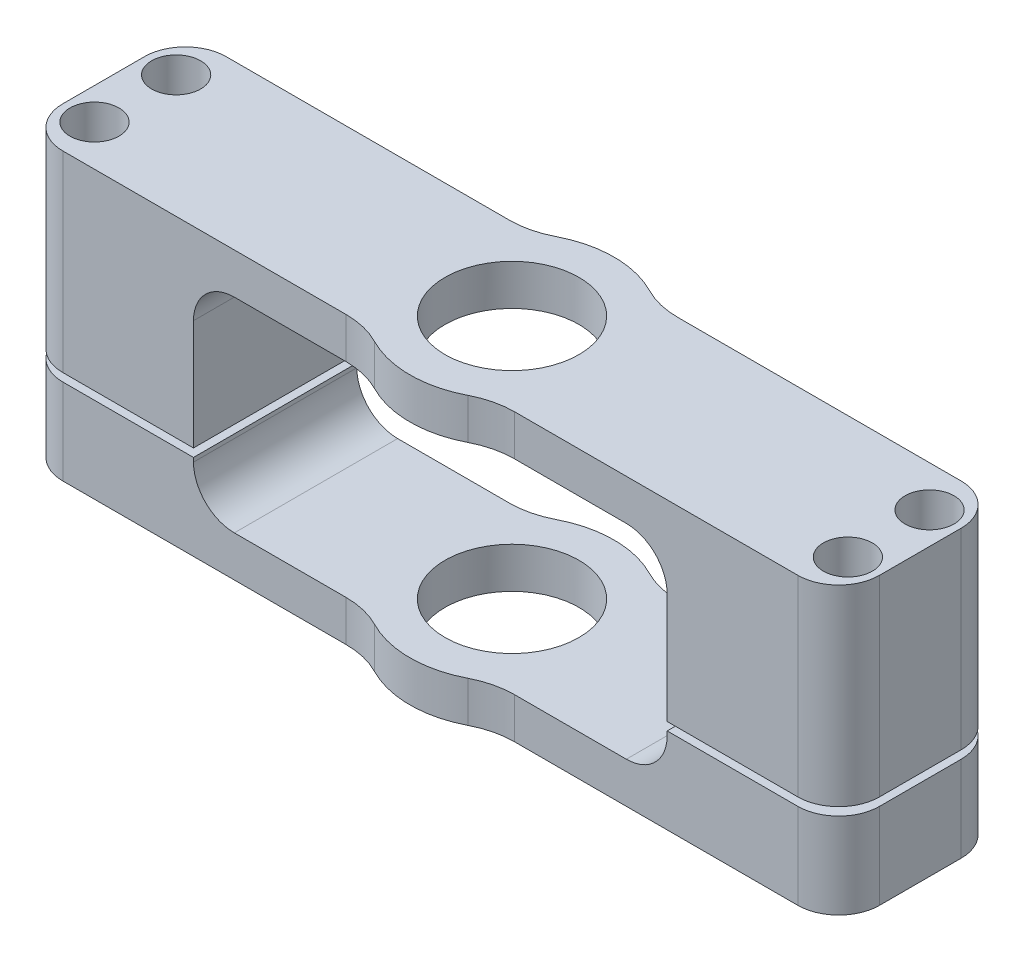
from build123d import *

# Parameters (mm, degrees)
SKETCH1_W               = 88
SKETCH1_H               = 20
BOSS_EXTRUDE1_DEPTH     = 35
SKETCH2_R               = 4.25
CUT_EXTRUDE1_DEPTH      = 21
SKETCH7_R               = 12.5
BOSS_EXTRUDE2_DEPTH     = 35
SKETCH4_R               = 8.2
CUT_EXTRUDE3_DEPTH      = 36
FILLET2_R               = 10
SKETCH10_W              = 58
SKETCH10_H              = 25
CUT_EXTRUDE5_DEPTH      = 13.5
CUT_EXTRUDE5_DEPTH_BACK = 13.5
FILLET3_R               = 5
SKETCH11_W              = 20
SKETCH11_H              = 35
BOSS_EXTRUDE3_DEPTH     = 6
SKETCH12_R              = 1.6
CUT_EXTRUDE6_DEPTH      = 36
FILLET5_R               = 5
SKETCH13_R              = 4.25
BOSS_EXTRUDE4_DEPTH     = 4
SKETCH14_W              = 100
SKETCH14_H              = 1
CUT_EXTRUDE7_DEPTH      = 23.5
SKETCH15_R              = 3
CUT_EXTRUDE8_DEPTH      = 6
CUT_EXTRUDE9_DEPTH      = 3


with BuildPart() as part:
    # Sketch1 → Boss-Extrude1 (new body)
    with BuildSketch(Plane(origin=(0, 0, 0), x_dir=(1, 0, 0), z_dir=(0, 1, 0))):
        Rectangle(SKETCH1_W, SKETCH1_H)
    extrude(amount=BOSS_EXTRUDE1_DEPTH)

    # Sketch2 → Cut-Extrude1 (cut, through all)
    with BuildSketch(Plane.XY.offset(10)):
        with Locations((-38, 11)):
            Circle(SKETCH2_R)
        with Locations((38, 11)):
            Circle(SKETCH2_R)
    extrude(amount=-CUT_EXTRUDE1_DEPTH, mode=Mode.SUBTRACT)

    # Sketch7 → Boss-Extrude2 (add)
    with BuildSketch(Plane(origin=(0, 35, 0), x_dir=(1, 0, 0), z_dir=(0, 1, 0))):
        Circle(SKETCH7_R)
    extrude(amount=-BOSS_EXTRUDE2_DEPTH)

    # Sketch4 → Cut-Extrude3 (cut, through all)
    with BuildSketch(Plane(origin=(0, 35, 0), x_dir=(1, 0, 0), z_dir=(0, 1, 0))):
        Circle(SKETCH4_R)
    extrude(amount=-CUT_EXTRUDE3_DEPTH, mode=Mode.SUBTRACT)

    # Fillet2
    fillet2_edges = [part.edges().sort_by_distance(p)[0] for p in [
        (7.5, 17.5, -10),
        (7.5, 17.5, 10),
        (-7.5, 17.5, -10),
        (-7.5, 17.5, 10),
    ]]
    fillet(fillet2_edges, radius=FILLET2_R)

    # Sketch10 → Cut-Extrude5 (cut, two sides)
    with BuildSketch(Plane.XY) as cut_extrude5_sk:
        with Locations((0, 17.5)):
            Rectangle(SKETCH10_W, SKETCH10_H)
    extrude(amount=CUT_EXTRUDE5_DEPTH, mode=Mode.SUBTRACT)
    extrude(cut_extrude5_sk.sketch, amount=-CUT_EXTRUDE5_DEPTH_BACK, mode=Mode.SUBTRACT)

    # Fillet3
    fillet3_edges = [part.edges().sort_by_distance(p)[0] for p in [
        (-29, 30, 0),
        (-29, 5, 0),
        (29, 30, 0),
        (29, 5, 0),
    ]]
    fillet(fillet3_edges, radius=FILLET3_R)

    # Sketch11 → Boss-Extrude3 (add)
    with BuildSketch(Plane(origin=(44, 0, 0), x_dir=(0, 0, -1), z_dir=(1, 0, 0))):
        with Locations((0, 17.5)):
            Rectangle(SKETCH11_W, SKETCH11_H)
    boss_extrude3 = extrude(amount=BOSS_EXTRUDE3_DEPTH)

    # Sketch12 → Cut-Extrude6 (cut, through all)
    with BuildSketch(Plane(origin=(0, 35, 0), x_dir=(1, 0, 0), z_dir=(0, 1, 0))):
        with Locations((46.124852936, 5)):
            Circle(SKETCH12_R)
        with Locations((46.124852936, -5)):
            Circle(SKETCH12_R)
    cut_extrude6 = extrude(amount=-CUT_EXTRUDE6_DEPTH, mode=Mode.SUBTRACT)

    # Mirror1: Boss-Extrude3, Cut-Extrude6 across plane
    add(boss_extrude3.mirror(Plane(origin=(0, 0, 0), x_dir=(0, 0, 1), z_dir=(1, 0, 0))))
    add(cut_extrude6.mirror(Plane(origin=(0, 0, 0), x_dir=(0, 0, 1), z_dir=(1, 0, 0))), mode=Mode.SUBTRACT)

    # Fillet5
    fillet5_edges = [part.edges().sort_by_distance(p)[0] for p in [
        (50, 17.5, -10),
        (50, 17.5, 10),
        (-50, 17.5, 10),
        (-50, 17.5, -10),
    ]]
    fillet(fillet5_edges, radius=FILLET5_R)

    # Sketch13 → Boss-Extrude4 (add)
    with BuildSketch(Plane.XY.offset(10)):
        with Locations((38, 11)):
            Circle(SKETCH13_R)
        with Locations((-38, 11)):
            Circle(SKETCH13_R)
    extrude(amount=-BOSS_EXTRUDE4_DEPTH)

    # Sketch14 → Cut-Extrude7 (cut, through all)
    with BuildSketch(Plane(origin=(0, 0, -10), x_dir=(-1, 0, 0), z_dir=(0, 0, -1))):
        with Locations((0, 11)):
            Rectangle(SKETCH14_W, SKETCH14_H)
    extrude(amount=-CUT_EXTRUDE7_DEPTH, mode=Mode.SUBTRACT)

    # Sketch15 → Cut-Extrude8 (cut)
    with BuildSketch(Plane(origin=(0, 35, 0), x_dir=(1, 0, 0), z_dir=(0, 1, 0))):
        with Locations((-46.124852936, 5)):
            Circle(SKETCH15_R)
        with Locations((-46.124852936, -5)):
            Circle(SKETCH15_R)
        with Locations((46.124852936, 5)):
            Circle(SKETCH15_R)
        with Locations((46.124852936, -5)):
            Circle(SKETCH15_R)
    extrude(amount=-CUT_EXTRUDE8_DEPTH, mode=Mode.SUBTRACT)

    # Sketch16 → Cut-Extrude9 (cut)
    with BuildSketch(Plane.XZ):
        Polygon((-42.949426456, 5), (-44.537139696, 7.75), (-47.712566176, 7.75), (-49.300279417, 5), (-47.712566176, 2.25), (-44.537139696, 2.25), align=None)
        Polygon((-42.949426456, -5), (-44.537139696, -2.25), (-47.712566176, -2.25), (-49.300279417, -5), (-47.712566176, -7.75), (-44.537139696, -7.75), align=None)
        Polygon((49.300279417, 5), (47.712566176, 7.75), (44.537139696, 7.75), (42.949426456, 5), (44.537139696, 2.25), (47.712566176, 2.25), align=None)
        Polygon((49.300279417, -5), (47.712566176, -2.25), (44.537139696, -2.25), (42.949426456, -5), (44.537139696, -7.75), (47.712566176, -7.75), align=None)
    extrude(amount=-CUT_EXTRUDE9_DEPTH, mode=Mode.SUBTRACT)


solid = part.part
